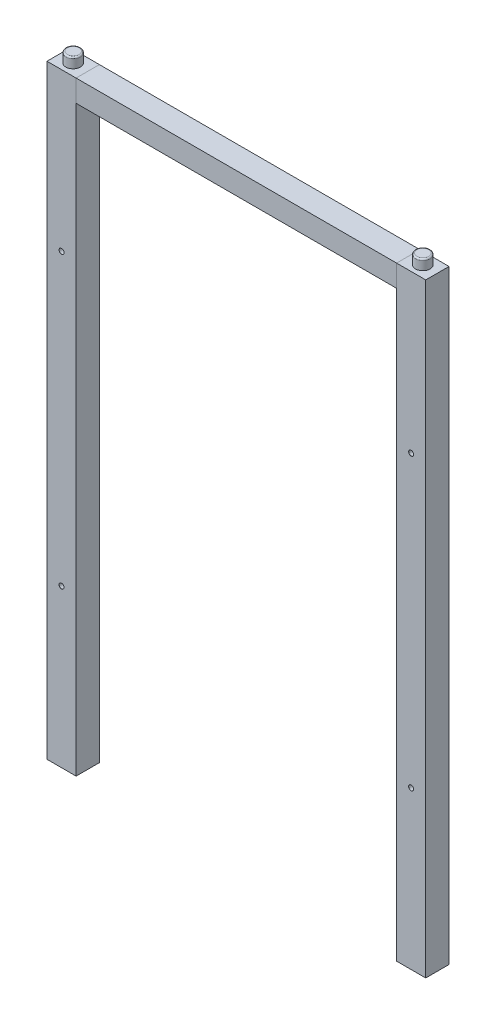
from build123d import *

# Parameters (mm, degrees)
SKETCH1_W                      = 16
SKETCH1_H                      = 415
BOSS_EXTRUDE1_DEPTH            = 20
SKETCH5_R                      = 5
BOSS_EXTRUDE2_DEPTH            = 7
FILLET1_R                      = 1
M3_CLEARANCE_HOLE1_D           = 3.4
M3_CLEARANCE_HOLE1_CSINK_D     = 3.45
M3_CLEARANCE_HOLE1_CSINK_ANGLE = 90
SKETCH8_W                      = 15
SKETCH8_H                      = 15
CUT_EXTRUDE1_DEPTH             = 7
SKETCH14_W                     = 220
SKETCH14_H                     = 15
BOSS_EXTRUDE3_DEPTH            = 16


with BuildPart() as part:
    # Sketch1 → Boss-Extrude1 (new body)
    with BuildSketch(Plane(origin=(0, 0, 0), x_dir=(0, 0, -1), z_dir=(1, 0, 0))):
        with Locations((8, -10.298148148)):
            Rectangle(SKETCH1_W, SKETCH1_H)
    extrude(amount=-BOSS_EXTRUDE1_DEPTH)

    # Sketch5 → Boss-Extrude2 (add)
    with BuildSketch(Plane(origin=(0, 197.201851852, 0), x_dir=(1, 0, 0), z_dir=(0, 1, 0))):
        with Locations((-10, 8)):
            Circle(SKETCH5_R)
    extrude(amount=BOSS_EXTRUDE2_DEPTH)

    # Fillet1
    fillet1_edges = [part.edges().sort_by_distance(p)[0] for p in [
        (-15, 204.201851852, -8),
    ]]
    fillet(fillet1_edges, radius=FILLET1_R)

    # M3 Clearance Hole1 (through all)
    with Locations(Plane(origin=(-10, 89.201851852, 0), x_dir=(1, 0, 0), z_dir=(0, 0, 1))):
        with Locations((0, 0), (0, -199)):
            CounterSinkHole(M3_CLEARANCE_HOLE1_D / 2, M3_CLEARANCE_HOLE1_CSINK_D / 2, counter_sink_angle=M3_CLEARANCE_HOLE1_CSINK_ANGLE)

    # Sketch8 → Cut-Extrude1 (cut)
    with BuildSketch(Plane.XZ.offset(217.798148148)):
        with Locations((-10, -8)):
            Rectangle(SKETCH8_W, SKETCH8_H)
    extrude(amount=-CUT_EXTRUDE1_DEPTH, mode=Mode.SUBTRACT)


with BuildPart() as body_2:
    # Mirror7: mirrored copy
    add(part.part.mirror(Plane.ZY.offset(-110)))


with BuildPart() as body_3:
    # Sketch14 → Boss-Extrude3 (new body)
    with BuildSketch(Plane.XY):
        with Locations((110, 189.701851852)):
            Rectangle(SKETCH14_W, SKETCH14_H)
    extrude(amount=-BOSS_EXTRUDE3_DEPTH)


solid = Compound([part.part, body_2.part, body_3.part])
